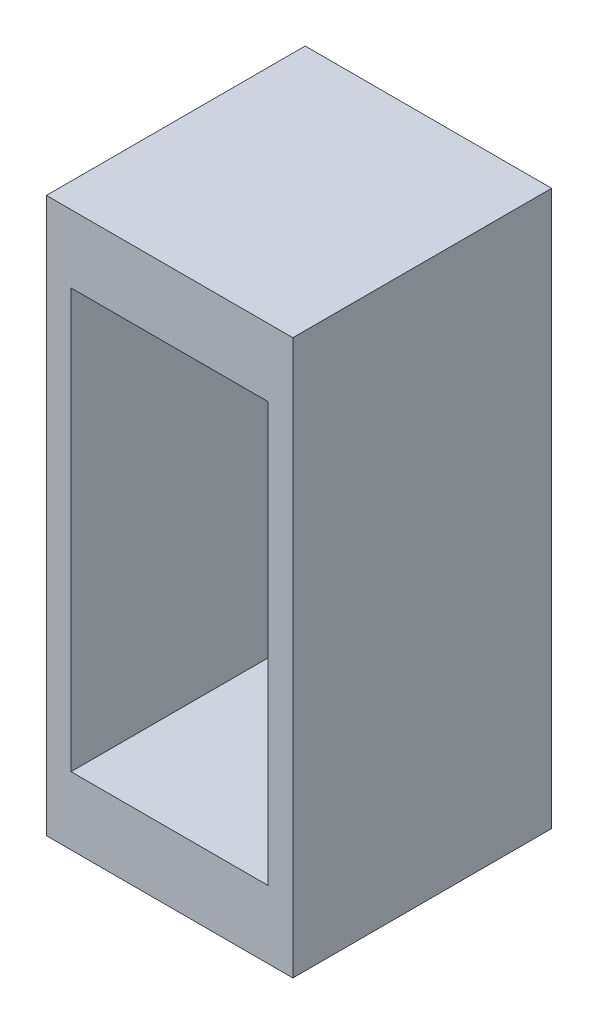
from build123d import *

# Parameters (mm, degrees)
SKETCH2_W           = 25.4
SKETCH2_H           = 57.15
SKETCH2_W_2         = 20.32
SKETCH2_H_2         = 43.18
BOSS_EXTRUDE2_DEPTH = 26.67
CUT_EXTRUDE1_REACH  = 59.15
SKETCH3_W           = 12.7
SKETCH3_H           = 12.7


with BuildPart() as part:
    # Sketch2 → Boss-Extrude2 (new body)
    with BuildSketch(Plane.XY):
        Rectangle(SKETCH2_W, SKETCH2_H)
        Rectangle(SKETCH2_W_2, SKETCH2_H_2, mode=Mode.SUBTRACT)
    extrude(amount=BOSS_EXTRUDE2_DEPTH)

    # Sketch3 → Cut-Extrude1 (cut, up to next)
    with BuildSketch(Plane.XZ.offset(28.575), mode=Mode.PRIVATE) as cut_extrude1_sk1:
        with Locations((0, -0.299628978)):
            Rectangle(SKETCH3_W, SKETCH3_H)
    cut_extrude1_tool1 = extrude(cut_extrude1_sk1.sketch, amount=-CUT_EXTRUDE1_REACH, mode=Mode.PRIVATE) & part.part
    add(cut_extrude1_tool1.solids().sort_by_distance((0, -28.575, -0.299629))[0], mode=Mode.SUBTRACT)


solid = part.part
